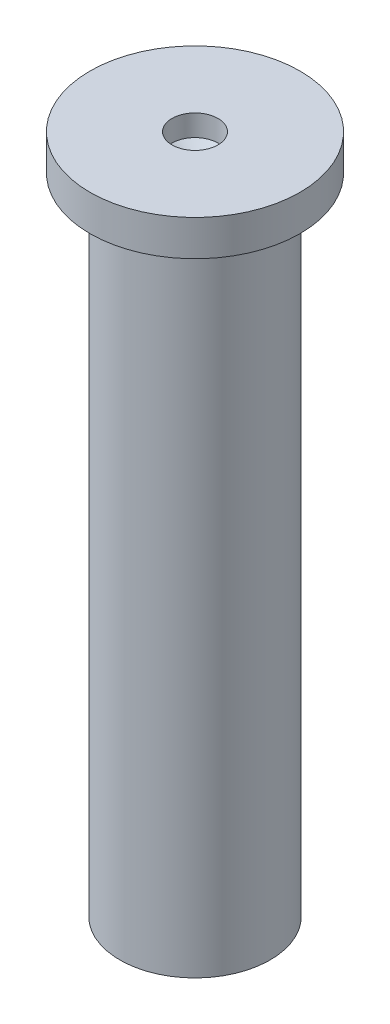
from build123d import *


with BuildPart() as part:
    # Sketch1 → Revolve1 (revolve)
    with BuildSketch(Plane.XY):
        Polygon((0, 0), (1.05, 0), (1.05, 9), (1.468172328, 9), (1.468172328, 9.5), (0.321215792, 9.5), (0.321215792, 9.20146171), (0, 9), align=None)
    revolve(axis=Axis((0, 0, 0), (0, 1, 0)))


solid = part.part
